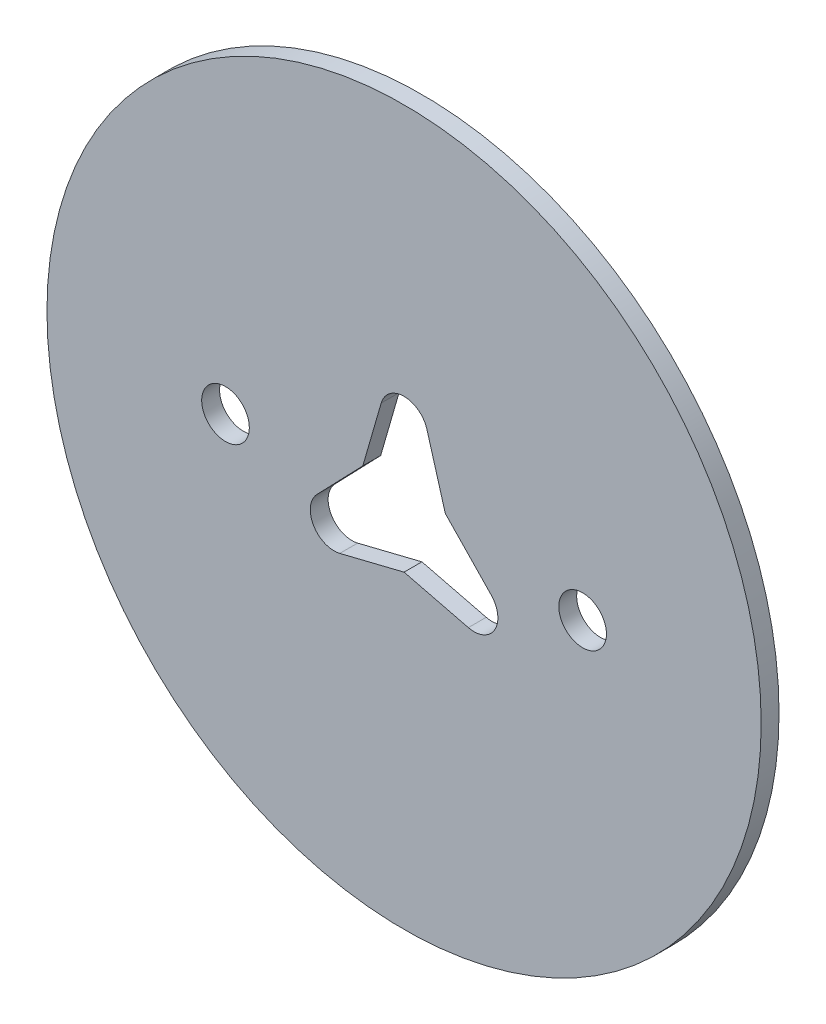
from build123d import *

# Parameters (mm, degrees)
SKETCH1_R           = 30
SKETCH1_R_2         = 2
BOSS_EXTRUDE1_DEPTH = 1.5
CUT_EXTRUDE1_DEPTH  = 10
FILLET1_R           = 2


with BuildPart() as part:
    # Sketch1 → Boss-Extrude1 (new body)
    with BuildSketch(Plane.XY):
        Circle(SKETCH1_R)
        with Locations((15, 0)):
            Circle(SKETCH1_R_2, mode=Mode.SUBTRACT)
        with Locations((-15, 0)):
            Circle(SKETCH1_R_2, mode=Mode.SUBTRACT)
    extrude(amount=BOSS_EXTRUDE1_DEPTH)

    # Sketch2 → Cut-Extrude1 (cut)
    with BuildSketch(Plane(origin=(0, 0, 0), x_dir=(-1, 0, 0), z_dir=(0, 0, -1))):
        Polygon((-12.124355653, -7), (-3.464101615, 2), (0, 14), (3.464101615, 2), (12.124355653, -7), (0, -4), align=None)
    extrude(amount=-CUT_EXTRUDE1_DEPTH, mode=Mode.SUBTRACT)

    # Fillet1
    fillet1_edges = [part.edges().sort_by_distance(p)[0] for p in [
        (-12.124355653, -7, 0.75),
        (12.124355653, -7, 0.75),
        (0, 14, 0.75),
    ]]
    fillet(fillet1_edges, radius=FILLET1_R)


solid = part.part
